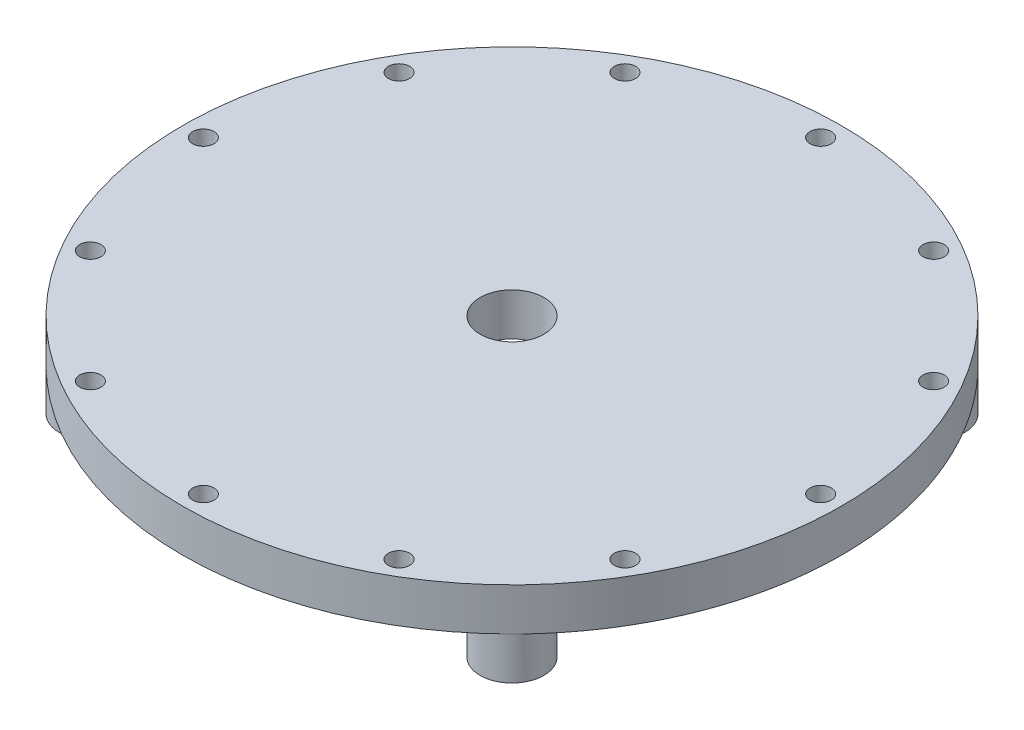
from build123d import *

# Parameters (mm, degrees)
SKETCH2_R               = 98.425
BOSS_EXTRUDE1_DEPTH     = 12.7
SKETCH3_R               = 9.525
CUT_EXTRUDE4_DEPTH      = 12.7
CUT_EXTRUDE4_DEPTH_BACK = 12.7
CUT_EXTRUDE9_START      = -2.54
SKETCH5_R               = 3.175
CUT_EXTRUDE9_DEPTH      = 15.24
CIRPATTERN1_COUNT       = 12
SKETCH6_R               = 9.525
BOSS_EXTRUDE2_DEPTH     = 12.7
CUT_EXTRUDE10_START     = -12.7
SKETCH8_R               = 3.175
CUT_EXTRUDE10_DEPTH     = 15.24
CIRPATTERN2_COUNT       = 4


with BuildPart() as part:
    # Sketch2 → Boss-Extrude1 (new body)
    with BuildSketch(Plane(origin=(0, 0, 0), x_dir=(1, 0, 0), z_dir=(0, 1, 0))):
        Circle(SKETCH2_R)
    extrude(amount=BOSS_EXTRUDE1_DEPTH)

    # Sketch3 → Cut-Extrude4 (cut, two sides)
    with BuildSketch(Plane(origin=(0, 0, 0), x_dir=(1, 0, 0), z_dir=(0, 1, 0))) as cut_extrude4_sk:
        Circle(SKETCH3_R)
    extrude(amount=CUT_EXTRUDE4_DEPTH, mode=Mode.SUBTRACT)
    extrude(cut_extrude4_sk.sketch, amount=-CUT_EXTRUDE4_DEPTH_BACK, mode=Mode.SUBTRACT)

    # Sketch5 → Cut-Extrude9 (cut)
    with BuildSketch(Plane(origin=(0, 0, 0), x_dir=(1, 0, 0), z_dir=(0, 1, 0)).offset(CUT_EXTRUDE9_START)):
        with Locations((0, -92.202)):
            Circle(SKETCH5_R)
    cut_extrude9 = extrude(amount=CUT_EXTRUDE9_DEPTH, mode=Mode.SUBTRACT)

    # CirPattern1: Cut-Extrude9 ×12 about axis
    cirpattern1_axis = Axis((0, 0, 0), (0, 1, 0))
    for i in range(1, CIRPATTERN1_COUNT):
        add(cut_extrude9.rotate(cirpattern1_axis, i * 360 / CIRPATTERN1_COUNT), mode=Mode.SUBTRACT)

    # Sketch6 → Boss-Extrude2 (add)
    with BuildSketch(Plane(origin=(0, 0, 0), x_dir=(-1, 0, 0), z_dir=(0, 1, 0))):
        with Locations((62.861792847, 62.861792847)):
            Circle(SKETCH6_R)
    boss_extrude2 = extrude(amount=-BOSS_EXTRUDE2_DEPTH)

    # Sketch8 → Cut-Extrude10 (cut)
    with BuildSketch(Plane(origin=(0, 0, 0), x_dir=(1, 0, 0), z_dir=(0, 1, 0)).offset(CUT_EXTRUDE10_START)):
        with Locations((-62.861792847, -62.861792847)):
            Circle(SKETCH8_R)
    cut_extrude10 = extrude(amount=CUT_EXTRUDE10_DEPTH, mode=Mode.SUBTRACT)

    # CirPattern2: Boss-Extrude2, Cut-Extrude10 ×4 about axis
    cirpattern2_axis = Axis((0, 0, 0), (0, 1, 0))
    for i in range(1, CIRPATTERN2_COUNT):
        add(boss_extrude2.rotate(cirpattern2_axis, i * 360 / CIRPATTERN2_COUNT))
        add(cut_extrude10.rotate(cirpattern2_axis, i * 360 / CIRPATTERN2_COUNT), mode=Mode.SUBTRACT)


solid = part.part
